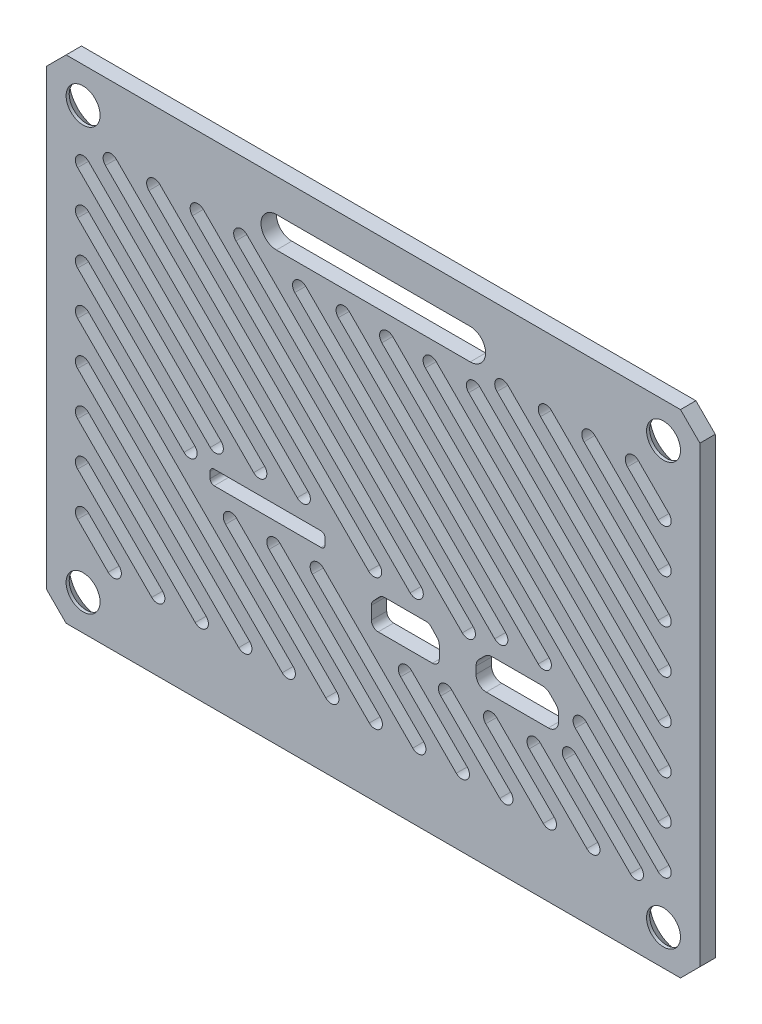
from build123d import *

# Parameters (mm, degrees)
SKETCH1_W           = 67.4
SKETCH1_H           = 50.8
BOSS_EXTRUDE1_DEPTH = 1.5875
CHAMFER1_SIZE       = 2
SKETCH3_R           = 1.75
CUT_EXTRUDE2_DEPTH  = 2.5875
CHAMFER2_SIZE       = 1.27
CUT_EXTRUDE4_DEPTH  = 2.5875
CUT_EXTRUDE5_DEPTH  = 1.5875
CUT_EXTRUDE6_DEPTH  = 2.5875


with BuildPart() as part:
    # Sketch1 → Boss-Extrude1 (new body)
    with BuildSketch(Plane.XY):
        with Locations((33.7, 25.4)):
            Rectangle(SKETCH1_W, SKETCH1_H)
    extrude(amount=BOSS_EXTRUDE1_DEPTH)

    # Chamfer1
    chamfer1_edges = [part.edges().sort_by_distance(p)[0] for p in [
        (0, 50.8, 0.79375),
        (67.4, 50.8, 0.79375),
        (67.4, 0, 0.79375),
        (0, 0, 0.79375),
    ]]
    chamfer(chamfer1_edges, length=CHAMFER1_SIZE)

    # Sketch3 → Cut-Extrude2 (cut, through all)
    with BuildSketch(Plane(origin=(0, 0, 0), x_dir=(-1, 0, 0), z_dir=(0, 0, -1))):
        with Locations((-63.65, 47.15)):
            Circle(SKETCH3_R)
        with Locations((-3.75, 47.15)):
            Circle(SKETCH3_R)
        with Locations((-3.75, 3.65)):
            Circle(SKETCH3_R)
        with Locations((-63.65, 3.65)):
            Circle(SKETCH3_R)
    extrude(amount=-CUT_EXTRUDE2_DEPTH, mode=Mode.SUBTRACT)

    # Chamfer2
    chamfer2_edges = [part.edges().sort_by_distance(p)[0] for p in [
        (65.4, 47.15, 0),
        (5.5, 47.15, 0),
        (5.5, 3.65, 0),
        (65.4, 3.65, 0),
    ]]
    chamfer(chamfer2_edges, length=CHAMFER2_SIZE)

    # Sketch5 → Cut-Extrude4 (cut, through all)
    with BuildSketch(Plane(origin=(0, 0, 0), x_dir=(-1, 0, 0), z_dir=(0, 0, -1))):
        with BuildLine():
            Line((-43.7, 47.3875), (-23.7, 47.3875))
            ThreePointArc((-23.7, 47.3875), (-22.1125, 45.8), (-23.7, 44.2125))
            Line((-23.7, 44.2125), (-43.7, 44.2125))
            ThreePointArc((-43.7, 44.2125), (-45.2875, 45.8), (-43.7, 47.3875))
        make_face()
    extrude(amount=-CUT_EXTRUDE4_DEPTH, mode=Mode.SUBTRACT)

    # Sketch6 → Cut-Extrude5 (cut)
    with BuildSketch(Plane(origin=(0, 0, 0), x_dir=(-1, 0, 0), z_dir=(0, 0, -1))):
        with BuildLine():
            Line((-17.2765, 19.9283), (-28.2965, 19.9283))
            ThreePointArc((-28.2965, 19.9283), (-28.596313275, 20.052486725), (-28.7205, 20.3523))
            Line((-28.7205, 20.3523), (-28.7205, 20.9923))
            ThreePointArc((-28.7205, 20.9923), (-28.596313275, 21.292113275), (-28.2965, 21.4163))
            Line((-28.2965, 21.4163), (-17.2765, 21.4163))
            ThreePointArc((-17.2765, 21.4163), (-16.976686725, 21.292113275), (-16.8525, 20.9923))
            Line((-16.8525, 20.9923), (-16.8525, 20.3523))
            ThreePointArc((-16.8525, 20.3523), (-16.976686725, 20.052486725), (-17.2765, 19.9283))
        make_face()
        with BuildLine():
            Line((-45.359056, 15.5295), (-51.759056, 15.5295))
            ThreePointArc((-51.759056, 15.5295), (-52.507174974, 15.839381026), (-52.817056, 16.5875))
            Line((-52.817056, 16.5875), (-52.817056, 17.333946609))
            ThreePointArc((-52.817056, 17.333946609), (-52.736520545, 17.738825681), (-52.507174974, 18.082065584))
            Line((-52.507174974, 18.082065584), (-51.903621584, 18.685618974))
            ThreePointArc((-51.903621584, 18.685618974), (-51.560381681, 18.914964545), (-51.155502609, 18.9955))
            Line((-51.155502609, 18.9955), (-45.962609391, 18.9955))
            ThreePointArc((-45.962609391, 18.9955), (-45.557730319, 18.914964545), (-45.214490416, 18.685618974))
            Line((-45.214490416, 18.685618974), (-44.610937026, 18.082065584))
            ThreePointArc((-44.610937026, 18.082065584), (-44.381591455, 17.738825681), (-44.301056, 17.333946609))
            Line((-44.301056, 17.333946609), (-44.301056, 16.5875))
            ThreePointArc((-44.301056, 16.5875), (-44.610937026, 15.839381026), (-45.359056, 15.5295))
        make_face()
        with BuildLine():
            Line((-34.20207, 15.3335), (-39.80207, 15.3335))
            ThreePointArc((-39.80207, 15.3335), (-40.299873174, 15.539696826), (-40.50607, 16.0375))
            Line((-40.50607, 16.0375), (-40.50607, 17.35769783))
            ThreePointArc((-40.50607, 17.35769783), (-40.456014569, 17.618413193), (-40.312966306, 17.842054067))
            Line((-40.312966306, 17.842054067), (-39.668478534, 18.521856238))
            ThreePointArc((-39.668478534, 18.521856238), (-39.435637267, 18.68426224), (-39.157582228, 18.7415))
            Line((-39.157582228, 18.7415), (-37.162069891, 18.7415))
            Line((-37.162069891, 18.7415), (-36.842069891, 18.7415))
            Line((-36.842069891, 18.7415), (-34.846557772, 18.7415))
            ThreePointArc((-34.846557772, 18.7415), (-34.568502733, 18.68426224), (-34.335661466, 18.521856238))
            Line((-34.335661466, 18.521856238), (-33.691173694, 17.842054067))
            ThreePointArc((-33.691173694, 17.842054067), (-33.548125431, 17.618413193), (-33.49807, 17.35769783))
            Line((-33.49807, 17.35769783), (-33.49807, 16.0375))
            ThreePointArc((-33.49807, 16.0375), (-33.704266826, 15.539696826), (-34.20207, 15.3335))
        make_face()
    extrude(amount=-CUT_EXTRUDE5_DEPTH, mode=Mode.SUBTRACT)

    # Sketch7 → Cut-Extrude6 (cut, through all)
    with BuildSketch(Plane(origin=(0, 0, 0), x_dir=(-1, 0, 0), z_dir=(0, 0, -1))):
        with BuildLine():
            Line((-3.188733992, 14.377581448), (-10.833831448, 6.732483992))
            ThreePointArc((-10.833831448, 6.732483992), (-11.956363463, 6.732483992), (-11.956363463, 7.855016008))
            Line((-11.956363463, 7.855016008), (-4.311266008, 15.500113463))
            ThreePointArc((-4.311266008, 15.500113463), (-3.188733992, 15.500113463), (-3.188733992, 14.377581448))
        make_face()
        with BuildLine():
            Line((-3.188733992, 9.887453387), (-6.343703387, 6.732483992))
            ThreePointArc((-6.343703387, 6.732483992), (-7.466235402, 6.732483992), (-7.466235402, 7.855016008))
            Line((-7.466235402, 7.855016008), (-4.311266008, 11.009985402))
            ThreePointArc((-4.311266008, 11.009985402), (-3.188733992, 11.009985402), (-3.188733992, 9.887453387))
        make_face()
        with BuildLine():
            Line((-3.188733992, 18.867709508), (-15.323959508, 6.732483992))
            ThreePointArc((-15.323959508, 6.732483992), (-16.446491523, 6.732483992), (-16.446491523, 7.855016008))
            Line((-16.446491523, 7.855016008), (-4.311266008, 19.990241523))
            ThreePointArc((-4.311266008, 19.990241523), (-3.188733992, 19.990241523), (-3.188733992, 18.867709508))
        make_face()
        with BuildLine():
            Line((-3.188733992, 23.357837569), (-19.814087569, 6.732483992))
            ThreePointArc((-19.814087569, 6.732483992), (-20.936619584, 6.732483992), (-20.936619584, 7.855016008))
            Line((-20.936619584, 7.855016008), (-4.311266008, 24.480369584))
            ThreePointArc((-4.311266008, 24.480369584), (-3.188733992, 24.480369584), (-3.188733992, 23.357837569))
        make_face()
        with BuildLine():
            Line((-3.188733992, 27.847965629), (-24.304215629, 6.732483992))
            ThreePointArc((-24.304215629, 6.732483992), (-25.426747644, 6.732483992), (-25.426747644, 7.855016008))
            Line((-25.426747644, 7.855016008), (-4.311266008, 28.970497644))
            ThreePointArc((-4.311266008, 28.970497644), (-3.188733992, 28.970497644), (-3.188733992, 27.847965629))
        make_face()
        with BuildLine():
            Line((-18.45354369, 17.073283992), (-28.79434369, 6.732483992))
            ThreePointArc((-28.79434369, 6.732483992), (-29.916875705, 6.732483992), (-29.916875705, 7.855016008))
            Line((-29.916875705, 7.855016008), (-19.576075705, 18.195816008))
            ThreePointArc((-19.576075705, 18.195816008), (-18.45354369, 18.195816008), (-18.45354369, 17.073283992))
        make_face()
        with BuildLine():
            Line((-22.94367175, 17.073283992), (-33.28447175, 6.732483992))
            ThreePointArc((-33.28447175, 6.732483992), (-34.407003765, 6.732483992), (-34.407003765, 7.855016008))
            Line((-34.407003765, 7.855016008), (-24.066203765, 18.195816008))
            ThreePointArc((-24.066203765, 18.195816008), (-22.94367175, 18.195816008), (-22.94367175, 17.073283992))
        make_face()
        with BuildLine():
            Line((-27.414849306, 17.092234497), (-37.774599811, 6.732483992))
            ThreePointArc((-37.774599811, 6.732483992), (-38.897131826, 6.732483992), (-38.897131826, 7.855016008))
            Line((-38.897131826, 7.855016008), (-28.537381321, 18.214766512))
            ThreePointArc((-28.537381321, 18.214766512), (-27.414849306, 18.214766512), (-27.414849306, 17.092234497))
        make_face()
        with BuildLine():
            Line((-3.188733992, 41.318349811), (-21.358299811, 23.148783992))
            ThreePointArc((-21.358299811, 23.148783992), (-22.480831826, 23.148783992), (-22.480831826, 24.271316008))
            Line((-22.480831826, 24.271316008), (-4.311266008, 42.440881826))
            ThreePointArc((-4.311266008, 42.440881826), (-3.188733992, 42.440881826), (-3.188733992, 41.318349811))
        make_face()
        with BuildLine():
            Line((-36.518727871, 12.478483992), (-42.264727871, 6.732483992))
            ThreePointArc((-42.264727871, 6.732483992), (-43.387259886, 6.732483992), (-43.387259886, 7.855016008))
            Line((-43.387259886, 7.855016008), (-37.641259886, 13.601016008))
            ThreePointArc((-37.641259886, 13.601016008), (-36.518727871, 13.601016008), (-36.518727871, 12.478483992))
        make_face()
        with BuildLine():
            Line((-6.052227871, 42.944983992), (-25.848427871, 23.148783992))
            ThreePointArc((-25.848427871, 23.148783992), (-26.970959887, 23.148783992), (-26.970959887, 24.271316008))
            Line((-26.970959887, 24.271316008), (-7.174759886, 44.067516008))
            ThreePointArc((-7.174759886, 44.067516008), (-6.052227871, 44.067516008), (-6.052227871, 42.944983992))
        make_face()
        with BuildLine():
            Line((-40.654553789, 12.832786135), (-46.754855932, 6.732483992))
            ThreePointArc((-46.754855932, 6.732483992), (-47.877387947, 6.732483992), (-47.877387947, 7.855016008))
            Line((-47.877387947, 7.855016008), (-41.777085804, 13.95531815))
            ThreePointArc((-41.777085804, 13.95531815), (-40.654553789, 13.95531815), (-40.654553789, 12.832786135))
        make_face()
        with BuildLine():
            Line((-45.302983992, 12.674483992), (-51.244983992, 6.732483992))
            ThreePointArc((-51.244983992, 6.732483992), (-52.367516008, 6.732483992), (-52.367516008, 7.855016008))
            Line((-52.367516008, 7.855016008), (-46.425516008, 13.797016008))
            ThreePointArc((-46.425516008, 13.797016008), (-45.302983992, 13.797016008), (-45.302983992, 12.674483992))
        make_face()
        with BuildLine():
            Line((-10.542355932, 42.944983992), (-33.212057351, 20.275282573))
            ThreePointArc((-33.212057351, 20.275282573), (-34.334589366, 20.275282573), (-34.334589366, 21.397814588))
            Line((-34.334589366, 21.397814588), (-11.664887947, 44.067516008))
            ThreePointArc((-11.664887947, 44.067516008), (-10.542355932, 44.067516008), (-10.542355932, 42.944983992))
        make_face()
        with BuildLine():
            Line((-15.032483992, 42.944983992), (-37.503483992, 20.473983992))
            ThreePointArc((-37.503483992, 20.473983992), (-38.626016008, 20.473983992), (-38.626016008, 21.596516008))
            Line((-38.626016008, 21.596516008), (-16.155016008, 44.067516008))
            ThreePointArc((-16.155016008, 44.067516008), (-15.032483992, 44.067516008), (-15.032483992, 42.944983992))
        make_face()
        with BuildLine():
            Line((-49.793112053, 12.674483992), (-55.735112053, 6.732483992))
            ThreePointArc((-55.735112053, 6.732483992), (-56.857644068, 6.732483992), (-56.857644068, 7.855016008))
            Line((-56.857644068, 7.855016008), (-50.915644068, 13.797016008))
            ThreePointArc((-50.915644068, 13.797016008), (-49.793112053, 13.797016008), (-49.793112053, 12.674483992))
        make_face()
        with BuildLine():
            Line((-53.430942047, 13.526782059), (-60.225240114, 6.732483992))
            ThreePointArc((-60.225240114, 6.732483992), (-61.347772129, 6.732483992), (-61.347772129, 7.855016008))
            Line((-61.347772129, 7.855016008), (-54.553474062, 14.649314075))
            ThreePointArc((-54.553474062, 14.649314075), (-53.430942047, 14.649314075), (-53.430942047, 13.526782059))
        make_face()
        with BuildLine():
            Line((-19.522612053, 42.944983992), (-42.881380852, 19.586215193))
            ThreePointArc((-42.881380852, 19.586215193), (-44.003912868, 19.586215193), (-44.003912868, 20.708747208))
            Line((-44.003912868, 20.708747208), (-20.645144068, 44.067516008))
            ThreePointArc((-20.645144068, 44.067516008), (-19.522612053, 44.067516008), (-19.522612053, 42.944983992))
        make_face()
        with BuildLine():
            Line((-25.600240114, 41.357483992), (-46.229740114, 20.727983992))
            ThreePointArc((-46.229740114, 20.727983992), (-47.352272129, 20.727983992), (-47.352272129, 21.850516008))
            Line((-47.352272129, 21.850516008), (-26.722772129, 42.480016008))
            ThreePointArc((-26.722772129, 42.480016008), (-25.600240114, 42.480016008), (-25.600240114, 41.357483992))
        make_face()
        with BuildLine():
            Line((-54.547091961, 16.900760205), (-63.088733992, 8.359118174))
            ThreePointArc((-63.088733992, 8.359118174), (-64.211266008, 8.359118174), (-64.211266008, 9.481650189))
            Line((-64.211266008, 9.481650189), (-55.669623976, 18.02329222))
            ThreePointArc((-55.669623976, 18.02329222), (-54.547091961, 18.02329222), (-54.547091961, 16.900760205))
        make_face()
        with BuildLine():
            Line((-34.580496235, 41.357483992), (-63.088733992, 12.849246235))
            ThreePointArc((-63.088733992, 12.849246235), (-64.211266008, 12.849246235), (-64.211266008, 13.97177825))
            Line((-64.211266008, 13.97177825), (-35.70302825, 42.480016008))
            ThreePointArc((-35.70302825, 42.480016008), (-34.580496235, 42.480016008), (-34.580496235, 41.357483992))
        make_face()
        with BuildLine():
            Line((-15.285221766, 22.486669946), (-4.311266008, 33.460625705))
            ThreePointArc((-4.311266008, 33.460625705), (-3.188733992, 33.460625705), (-3.188733992, 32.33809369))
            Line((-3.188733992, 32.33809369), (-14.162689751, 21.364137931))
            ThreePointArc((-14.162689751, 21.364137931), (-15.285221766, 21.364137931), (-15.285221766, 22.486669946))
        make_face()
        with BuildLine():
            Line((-3.188733992, 36.82822175), (-16.86817175, 23.148783992))
            ThreePointArc((-16.86817175, 23.148783992), (-17.990703765, 23.148783992), (-17.990703765, 24.271316008))
            Line((-17.990703765, 24.271316008), (-4.311266008, 37.950753765))
            ThreePointArc((-4.311266008, 37.950753765), (-3.188733992, 37.950753765), (-3.188733992, 36.82822175))
        make_face()
        with BuildLine():
            Line((-39.070624295, 41.357483992), (-63.088733992, 17.339374295))
            ThreePointArc((-63.088733992, 17.339374295), (-64.211266008, 17.339374295), (-64.211266008, 18.46190631))
            Line((-64.211266008, 18.46190631), (-40.19315631, 42.480016008))
            ThreePointArc((-40.19315631, 42.480016008), (-39.070624295, 42.480016008), (-39.070624295, 41.357483992))
        make_face()
        with BuildLine():
            Line((-43.539958361, 41.378277987), (-63.088733992, 21.829502356))
            ThreePointArc((-63.088733992, 21.829502356), (-64.211266008, 21.829502356), (-64.211266008, 22.952034371))
            Line((-64.211266008, 22.952034371), (-44.662490376, 42.500810002))
            ThreePointArc((-44.662490376, 42.500810002), (-43.539958361, 42.500810002), (-43.539958361, 41.378277987))
        make_face()
        with BuildLine():
            Line((-46.463380416, 42.944983992), (-63.088733992, 26.319630416))
            ThreePointArc((-63.088733992, 26.319630416), (-64.211266008, 26.319630416), (-64.211266008, 27.442162431))
            Line((-64.211266008, 27.442162431), (-47.585912431, 44.067516008))
            ThreePointArc((-47.585912431, 44.067516008), (-46.463380416, 44.067516008), (-46.463380416, 42.944983992))
        make_face()
        with BuildLine():
            Line((-50.953508477, 42.944983992), (-63.088733992, 30.809758477))
            ThreePointArc((-63.088733992, 30.809758477), (-64.211266008, 30.809758477), (-64.211266008, 31.932290492))
            Line((-64.211266008, 31.932290492), (-52.076040492, 44.067516008))
            ThreePointArc((-52.076040492, 44.067516008), (-50.953508477, 44.067516008), (-50.953508477, 42.944983992))
        make_face()
        with BuildLine():
            Line((-55.443636537, 42.944983992), (-63.088733992, 35.299886537))
            ThreePointArc((-63.088733992, 35.299886537), (-64.211266008, 35.299886537), (-64.211266008, 36.422418552))
            Line((-64.211266008, 36.422418552), (-56.566168552, 44.067516008))
            ThreePointArc((-56.566168552, 44.067516008), (-55.443636537, 44.067516008), (-55.443636537, 42.944983992))
        make_face()
        with BuildLine():
            Line((-59.933764598, 42.944983992), (-63.088733992, 39.790014598))
            ThreePointArc((-63.088733992, 39.790014598), (-64.211266008, 39.790014598), (-64.211266008, 40.912546613))
            Line((-64.211266008, 40.912546613), (-61.056296613, 44.067516008))
            ThreePointArc((-61.056296613, 44.067516008), (-59.933764598, 44.067516008), (-59.933764598, 42.944983992))
        make_face()
        with BuildLine():
            Line((-30.090368174, 41.357483992), (-50.719868174, 20.727983992))
            ThreePointArc((-50.719868174, 20.727983992), (-51.842400189, 20.727983992), (-51.842400189, 21.850516008))
            Line((-51.842400189, 21.850516008), (-31.212900189, 42.480016008))
            ThreePointArc((-31.212900189, 42.480016008), (-30.090368174, 42.480016008), (-30.090368174, 41.357483992))
        make_face()
    extrude(amount=-CUT_EXTRUDE6_DEPTH, mode=Mode.SUBTRACT)


solid = part.part
